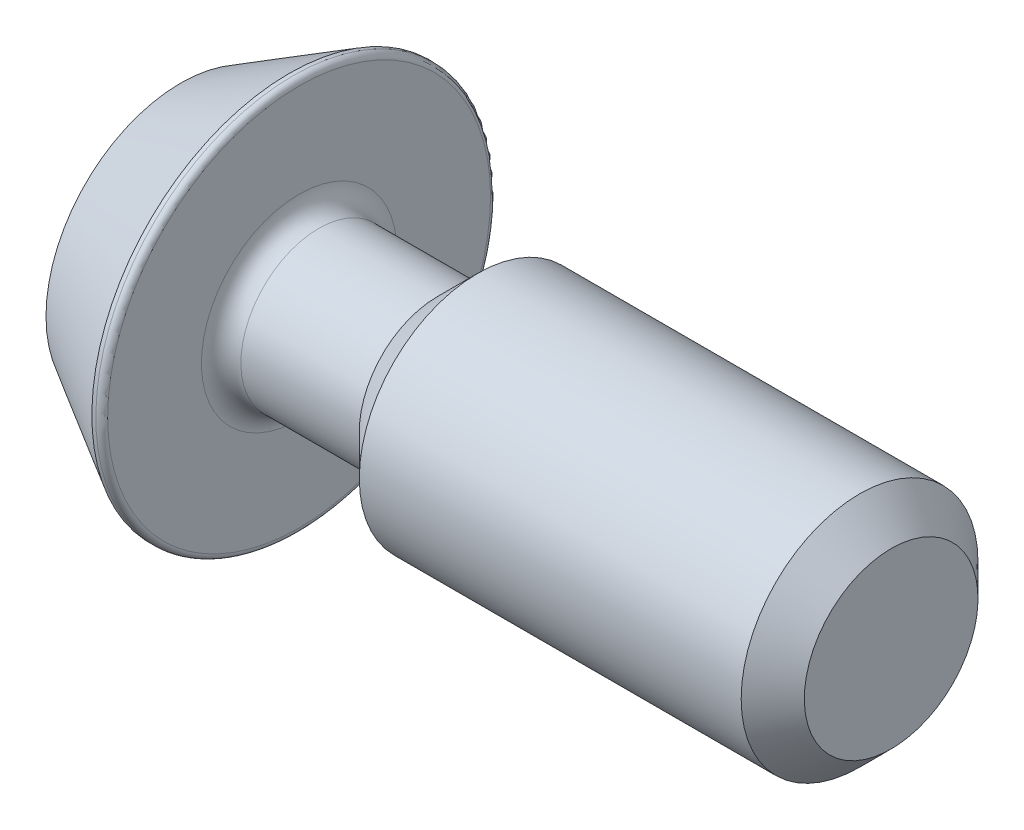
from build123d import *

# Parameters (mm, degrees)
CUT_EXTRUDE_1_DEPTH = 4
FILLET_1_R          = 0.3
CHAMFER_1_SIZE      = 1.6
FILLET_2_R          = 1


with BuildPart() as part:
    # Эскиз1 → Повернуть1 (revolve)
    with BuildSketch(Plane.XY):
        Polygon((0, 0), (0, 6.824573519), (5.5, 10), (6, 10), (6, 3.95), (13, 3.95), (15.05, 6), (36, 6), (36, 0), align=None)
    revolve(axis=Axis((36, 0, 0), (-1, 0, 0)))

    # Эскиз2 → Вырез-Вытянуть1 (cut)
    with BuildSketch(Plane.ZY):
        Polygon((1.732050808, 3), (-1.732050808, 3), (-3.464101615, 0), (-1.732050808, -3), (1.732050808, -3), (3.464101615, 0), align=None)
    extrude(amount=-CUT_EXTRUDE_1_DEPTH, mode=Mode.SUBTRACT)

    # Скругление1
    fillet_1_edges = [part.edges().sort_by_distance(p)[0] for p in [
        (6, -10, 0),
    ]]
    fillet(fillet_1_edges, radius=FILLET_1_R)

    # Фаска1
    chamfer_1_edges = [part.edges().sort_by_distance(p)[0] for p in [
        (36, -6, 0),
    ]]
    chamfer(chamfer_1_edges, length=CHAMFER_1_SIZE)

    # Скругление2
    fillet_2_edges = [part.edges().sort_by_distance(p)[0] for p in [
        (6, -3.95, 0),
    ]]
    fillet(fillet_2_edges, radius=FILLET_2_R)


solid = part.part
